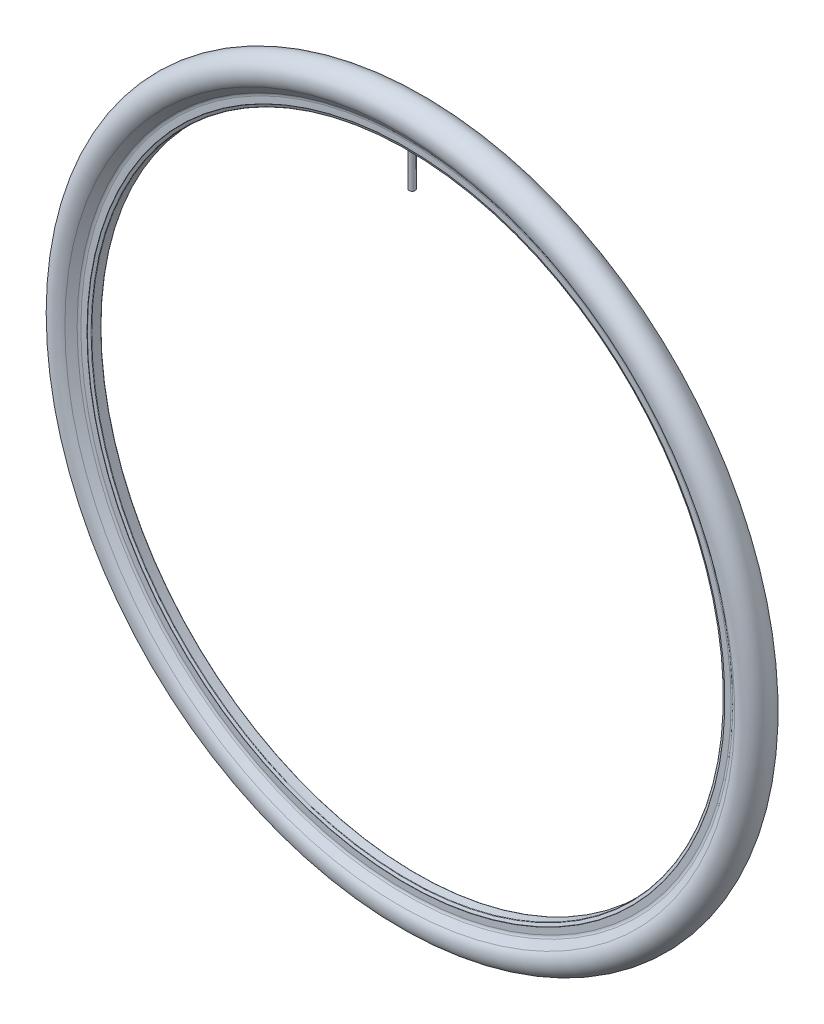
from build123d import *

# Parameters (mm, degrees)
EXTRUSION1_REACH             = 623.5
EXTRUSION1_END_RADIUS        = 307
EXTRUSION1_START             = 272
ESQUISSE2_R                  = 3
ENL_V_MAT_EXTRU_1_REACH      = 79.5
ENL_V_MAT_EXTRU_1_END_RADIUS = 308
ESQUISSE3_R                  = 1.25


with BuildPart() as part:
    # Esquisse1 → Révolution1 (revolve)
    with BuildSketch(Plane.ZY, mode=Mode.PRIVATE) as r_volution1_sk:
        with BuildLine():
            Line((6, 316.000025307), (6, 310))
            ThreePointArc((6, 310), (5.896502914, 309.903551237), (5.824163529, 309.781974001))
            Line((5.824163529, 309.781974001), (4.793205526, 307.30769122))
            ThreePointArc((4.793205526, 307.30769122), (4.609017126, 307.083974526), (4.331667518, 307))
            Line((4.331667518, 307), (-4.331667518, 307))
            ThreePointArc((-4.331667518, 307), (-4.609017126, 307.083974526), (-4.793205526, 307.30769122))
            Line((-4.793205526, 307.30769122), (-5.824163529, 309.781974001))
            ThreePointArc((-5.824163529, 309.781974001), (-5.896502914, 309.903551237), (-6, 310))
            Line((-6, 310), (-6, 316.000025307))
            ThreePointArc((-6, 316.000025307), (-6.23092643, 317.423054068), (-6.900004823, 318.700031739))
            Line((-6.900004823, 318.700031739), (-11.999983922, 325.499978563))
            ThreePointArc((-11.999983922, 325.499978563), (0, 349.5), (11.999983922, 325.499978563))
            Line((11.999983922, 325.499978563), (6.900004823, 318.700031739))
            ThreePointArc((6.900004823, 318.700031739), (6.23092643, 317.423054068), (6, 316.000025307))
        make_face()
        with BuildLine():
            Line((-6.100005895, 319.300033168), (-11.199984994, 326.099979992))
            ThreePointArc((-11.199984994, 326.099979992), (0, 348.5), (11.199984994, 326.099979992))
            Line((11.199984994, 326.099979992), (6.100005895, 319.300033168))
            ThreePointArc((6.100005895, 319.300033168), (5.282243414, 317.739282681), (5, 316.000025307))
            Line((5, 316.000025307), (5, 310.362304564))
            ThreePointArc((5, 310.362304564), (4.946962506, 310.266258011), (4.901087513, 310.166591561))
            Line((4.901087513, 310.166591561), (4.023976141, 308.061538244))
            ThreePointArc((4.023976141, 308.061538244), (3.987138461, 308.016794905), (3.931668539, 308))
            Line((3.931668539, 308), (-3.931668539, 308))
            ThreePointArc((-3.931668539, 308), (-3.987138461, 308.016794905), (-4.023976141, 308.061538244))
            Line((-4.023976141, 308.061538244), (-4.901087513, 310.166591561))
            ThreePointArc((-4.901087513, 310.166591561), (-4.946962506, 310.266258011), (-5, 310.362304564))
            Line((-5, 310.362304564), (-5, 316.000025307))
            ThreePointArc((-5, 316.000025307), (-5.282243414, 317.739282681), (-6.100005895, 319.300033168))
        make_face(mode=Mode.SUBTRACT)
    revolve(r_volution1_sk.sketch.rotate(Axis((0, 0, -66.492489003), (0, 0, 1)), 90), axis=Axis((0, 0, -66.492489003), (0, 0, 1)))  # turned: the seam where the file's is

    # Extrusion1: up to this cylinder (the profile starts inside it)
    extrusion1_end = Plane(origin=(0, 0, 0), z_dir=(0, 0, -1)) * Cylinder(EXTRUSION1_END_RADIUS, 1862, mode=Mode.PRIVATE)
    # Esquisse2 → Extrusion1 (add, up to the surface)
    with BuildSketch(Plane(origin=(0, 0, 0), x_dir=(1, 0, 0), z_dir=(0, 1, 0)).offset(EXTRUSION1_START), mode=Mode.PRIVATE) as extrusion1_sk1:
        with Locations(Location((0, 0, 0), (0, 0, 90))):  # turned: the seam where the file's is
            Circle(ESQUISSE2_R)
    extrusion1_tool1 = extrude(extrusion1_sk1.sketch, amount=EXTRUSION1_REACH, mode=Mode.PRIVATE) & extrusion1_end
    add(extrusion1_tool1.solids().sort_by_distance((0, 272, 0))[0])

    # Enlèv. mat.-Extru.1: up to this cylinder (the profile starts inside it)
    enl_v_mat_extru_1_end = Plane(origin=(0, 0, 0), z_dir=(0, 0, -1)) * Cylinder(ENL_V_MAT_EXTRU_1_END_RADIUS, 776, mode=Mode.PRIVATE)
    # Esquisse3 → Enlèv. mat.-Extru.1 (cut, up to the surface)
    with BuildSketch(Plane.XZ.offset(-272), mode=Mode.PRIVATE) as enl_v_mat_extru_1_sk1:
        with Locations(Location((0, 0, 0), (0, 0, 270))):  # turned: the seam where the file's is
            Circle(ESQUISSE3_R)
    enl_v_mat_extru_1_tool1 = extrude(enl_v_mat_extru_1_sk1.sketch, amount=-ENL_V_MAT_EXTRU_1_REACH, mode=Mode.PRIVATE) & enl_v_mat_extru_1_end
    add(enl_v_mat_extru_1_tool1.solids().sort_by_distance((0, 272, 0))[0], mode=Mode.SUBTRACT)


solid = part.part
